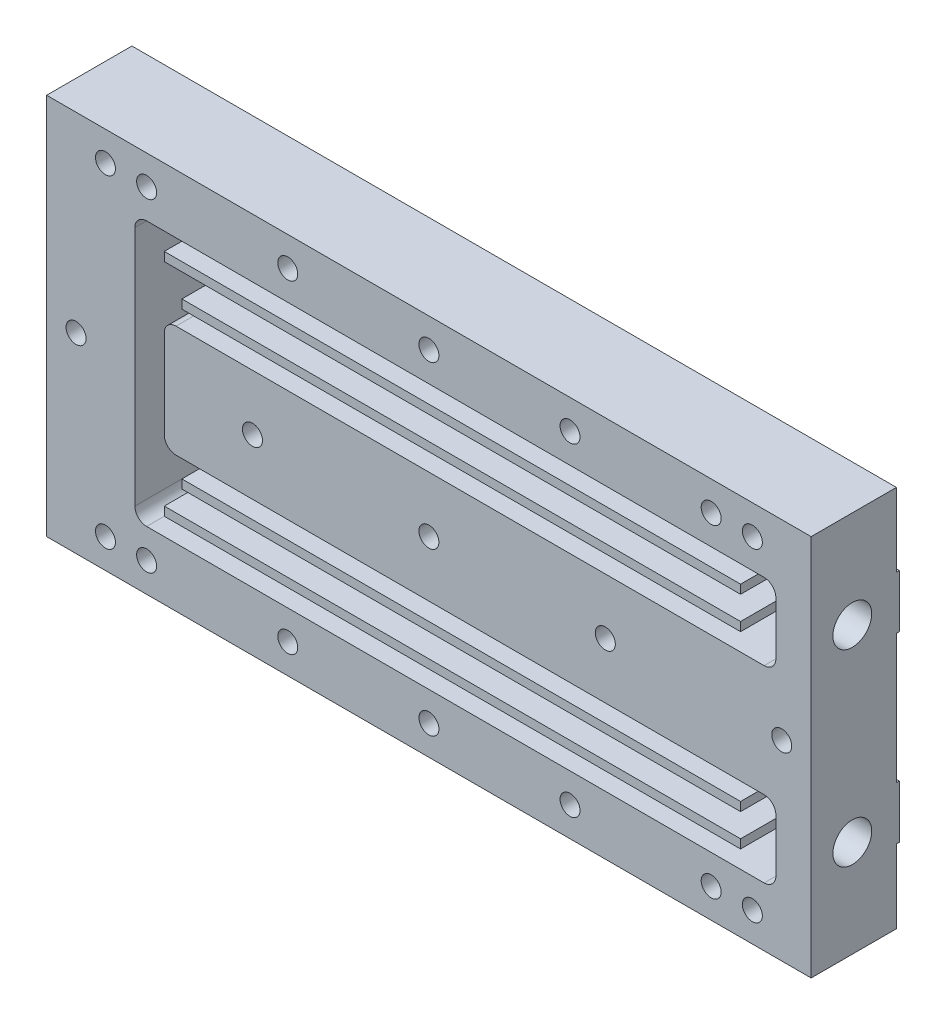
from build123d import *

# Parameters (mm, degrees)
ESQUISSE1_W             = 130
ESQUISSE1_H             = 65
ESQUISSE1_R             = 1.3
BOSS_EXTRU_1_DEPTH      = 15
ESQUISSE2_W             = 130
ESQUISSE2_H             = 12.5
ESQUISSE2_H_2           = 22
ENL_V_MAT_EXTRU_1_DEPTH = 0.5
ESQUISSE5_R             = 1.3
ENL_V_MAT_EXTRU_2_DEPTH = 15.5
D_GAGEMENT_M31_D        = 3.4
ENL_V_MAT_EXTRU_3_DEPTH = 12
D_GAGEMENT_M61_D        = 6.6
D_GAGEMENT_M61_DEPTH    = 10
D_GAGEMENT_M61_TIP      = 1.982840043
ESQUISSE16_W            = 98
ESQUISSE16_H            = 1.5
ESQUISSE16_W_2          = 95
BOSS_EXTRU_2_DEPTH      = 12


with BuildPart() as part:
    # Esquisse1 → Boss.-Extru.1 (new body)
    with BuildSketch(Plane.XY):
        with Locations((65, 32.5)):
            Rectangle(ESQUISSE1_W, ESQUISSE1_H)
        with Locations((113, 5)):
            Circle(ESQUISSE1_R, mode=Mode.SUBTRACT)
        with Locations((89, 5)):
            Circle(ESQUISSE1_R, mode=Mode.SUBTRACT)
        with Locations((65, 5)):
            Circle(ESQUISSE1_R, mode=Mode.SUBTRACT)
        with Locations((41, 5)):
            Circle(ESQUISSE1_R, mode=Mode.SUBTRACT)
        with Locations((17, 5)):
            Circle(ESQUISSE1_R, mode=Mode.SUBTRACT)
        with Locations((113, 60)):
            Circle(ESQUISSE1_R, mode=Mode.SUBTRACT)
        with Locations((89, 60)):
            Circle(ESQUISSE1_R, mode=Mode.SUBTRACT)
        with Locations((65, 60)):
            Circle(ESQUISSE1_R, mode=Mode.SUBTRACT)
        with Locations((41, 60)):
            Circle(ESQUISSE1_R, mode=Mode.SUBTRACT)
        with Locations((17, 60)):
            Circle(ESQUISSE1_R, mode=Mode.SUBTRACT)
    extrude(amount=BOSS_EXTRU_1_DEPTH)

    # Esquisse2 → Enlèv. mat.-Extru.1 (cut)
    with BuildSketch(Plane(origin=(0, 0, 0), x_dir=(-1, 0, 0), z_dir=(0, 0, -1))):
        with Locations((-65, 58.75)):
            Rectangle(ESQUISSE2_W, ESQUISSE2_H)
        with Locations((-65, 6.25)):
            Rectangle(ESQUISSE2_W, ESQUISSE2_H)
        with Locations((-65, 32.5)):
            Rectangle(ESQUISSE2_W, ESQUISSE2_H_2)
    extrude(amount=-ENL_V_MAT_EXTRU_1_DEPTH, mode=Mode.SUBTRACT)

    # Esquisse5 → Enlèv. mat.-Extru.2 (cut, through all)
    with BuildSketch(Plane(origin=(0, 0, 0.5), x_dir=(-1, 0, 0), z_dir=(0, 0, -1))):
        with Locations((-95, 32.5)):
            Circle(ESQUISSE5_R)
        with Locations((-65, 32.5)):
            Circle(ESQUISSE5_R)
        with Locations((-125, 32.5)):
            Circle(ESQUISSE5_R)
        with Locations((-5, 32.5)):
            Circle(ESQUISSE5_R)
        with Locations((-10, 60)):
            Circle(ESQUISSE5_R)
        with Locations((-10, 5)):
            Circle(ESQUISSE5_R)
        with Locations((-120, 60)):
            Circle(ESQUISSE5_R)
        with Locations((-120, 5)):
            Circle(ESQUISSE5_R)
        with Locations((-35, 32.5)):
            Circle(ESQUISSE5_R)
    extrude(amount=-ENL_V_MAT_EXTRU_2_DEPTH, mode=Mode.SUBTRACT)

    # Dégagement M31 (through all)
    with Locations(Plane.XY.offset(15)):
        with Locations((17, 60), (41, 60), (65, 60), (89, 60), (113, 60), (125, 32.5), (95, 32.5), (65, 32.5), (5, 32.5), (17, 5), (41, 5), (65, 5), (89, 5), (113, 5), (10, 60), (10, 5), (120, 5), (120, 60), (35, 32.5)):
            Hole(D_GAGEMENT_M31_D / 2)

    # Esquisse12 → Enlèv. mat.-Extru.3 (cut)
    with BuildSketch(Plane.XY.offset(15)):
        with BuildLine():
            Line((122, 55), (17, 55))
            ThreePointArc((17, 55), (15.585786438, 54.414213562), (15, 53))
            Line((15, 53), (15, 12))
            ThreePointArc((15, 12), (15.585786438, 10.585786438), (17, 10))
            Line((17, 10), (122, 10))
            ThreePointArc((122, 10), (123.414213562, 10.585786438), (124, 12))
            Line((124, 12), (124, 21))
            ThreePointArc((124, 21), (123.414213562, 22.414213562), (122, 23))
            Line((122, 23), (22, 23))
            ThreePointArc((22, 23), (20.585786438, 23.585786438), (20, 25))
            Line((20, 25), (20, 40))
            ThreePointArc((20, 40), (20.585786438, 41.414213562), (22, 42))
            Line((22, 42), (122, 42))
            ThreePointArc((122, 42), (123.414213562, 42.585786438), (124, 44))
            Line((124, 44), (124, 53))
            ThreePointArc((124, 53), (123.414213562, 54.414213562), (122, 55))
        make_face()
    extrude(amount=-ENL_V_MAT_EXTRU_3_DEPTH, mode=Mode.SUBTRACT)

    # Dégagement M61
    with Locations(Plane(origin=(130, 0, 0), x_dir=(0, 0, -1), z_dir=(1, 0, 0))):
        with Locations((-8, 48.5), (-8, 16.5)):
            Hole(D_GAGEMENT_M61_D / 2, depth=D_GAGEMENT_M61_DEPTH)
            with Locations((0, 0, -(D_GAGEMENT_M61_DEPTH + D_GAGEMENT_M61_TIP / 2))):  # 118° drill point
                Cone(0, D_GAGEMENT_M61_D / 2, D_GAGEMENT_M61_TIP, mode=Mode.SUBTRACT)

    # Esquisse16 → Boss.-Extru.2 (add)
    with BuildSketch(Plane.XY.offset(3)):
        with Locations((69, 51.25)):
            Rectangle(ESQUISSE16_W, ESQUISSE16_H)
        with Locations((70.5, 45.75)):
            Rectangle(ESQUISSE16_W_2, ESQUISSE16_H)
        with Locations((70.5, 19.25)):
            Rectangle(ESQUISSE16_W_2, ESQUISSE16_H)
        with Locations((69, 13.75)):
            Rectangle(ESQUISSE16_W, ESQUISSE16_H)
    extrude(amount=BOSS_EXTRU_2_DEPTH)


solid = part.part
